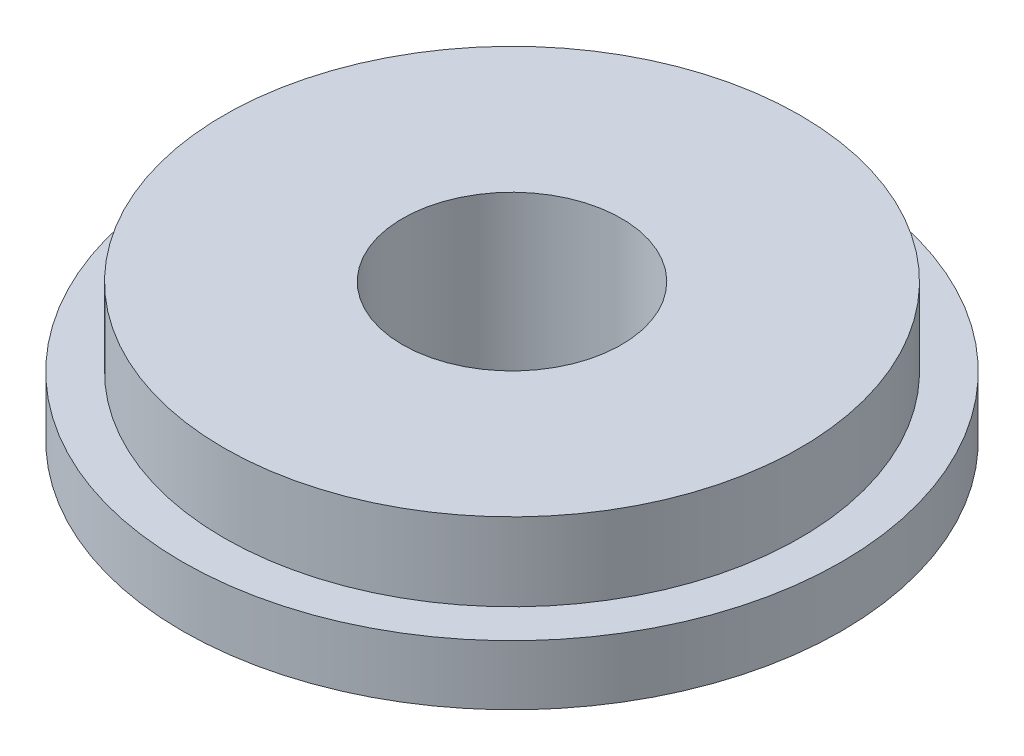
from build123d import *

# Parameters (mm, degrees)
SKETCH1_R         = 12.7
EXTRUDE1_DEPTH    = 9
SKETCH2_R         = 4.2164
EXTRUDE2_DEPTH    = 25.4
SKETCH3_OUTSIDE_W = 34.806
SKETCH3_OUTSIDE_H = 34.806
SKETCH3_OUTSIDE_R = 11.1
EXTRUDE3_DEPTH    = 3


with BuildPart() as part:
    # Sketch1 → Extrude1 (new body)
    with BuildSketch(Plane(origin=(0, 0, 0), x_dir=(1, 0, 0), z_dir=(0, 1, 0))):
        Circle(SKETCH1_R)
    extrude(amount=EXTRUDE1_DEPTH)

    # Sketch2 → Extrude2 (cut)
    with BuildSketch(Plane(origin=(0, 0, 0), x_dir=(1, 0, 0), z_dir=(0, 1, 0))):
        Circle(SKETCH2_R)
    extrude(amount=EXTRUDE2_DEPTH, mode=Mode.SUBTRACT)

    # Sketch3 outside → Extrude3 (cut)
    with BuildSketch(Plane(origin=(0, 9, 0), x_dir=(1, 0, 0), z_dir=(0, 1, 0))):
        Rectangle(SKETCH3_OUTSIDE_W, SKETCH3_OUTSIDE_H)
        Circle(SKETCH3_OUTSIDE_R, mode=Mode.SUBTRACT)
    extrude(amount=-EXTRUDE3_DEPTH, mode=Mode.SUBTRACT)

    # Sketch6 → Cut-Revolve1 (revolve, cut)
    with BuildSketch(Plane(origin=(0, 0, 0), x_dir=(0, 0, -1), z_dir=(1, 0, 0))):
        Polygon((-1.103847577, -3), (-15, 5.022947342), (-15, -3), align=None)
    revolve(axis=Axis((0, 0, 0), (0, -1, 0)), mode=Mode.SUBTRACT)


solid = part.part
